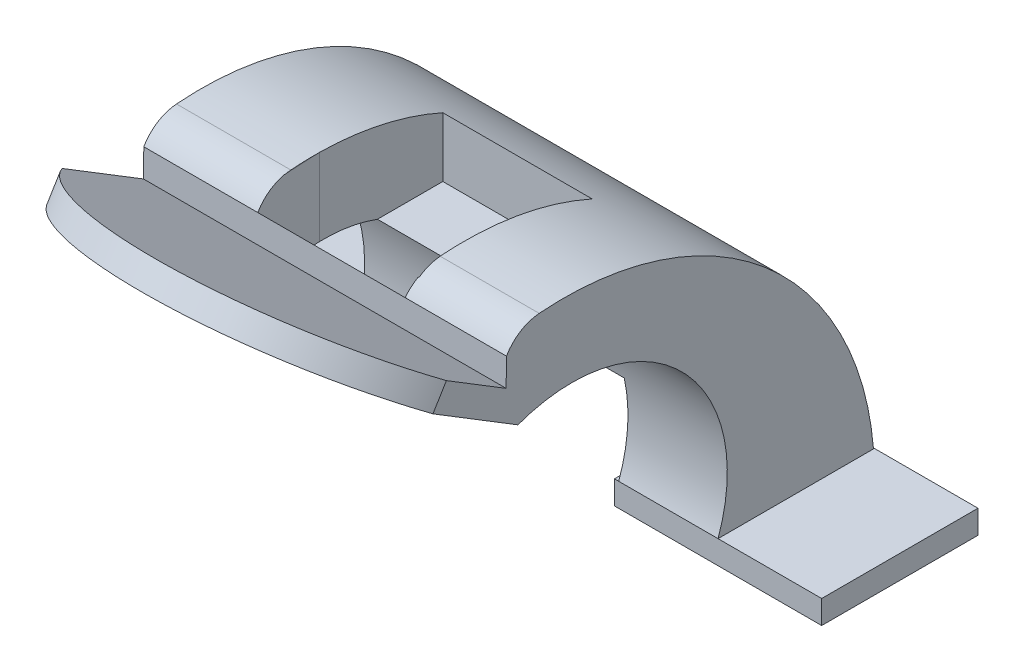
from build123d import *

# Parameters (mm, degrees)
BOSS_EXTRUDE4_DEPTH      = 70
CUT_EXTRUDE7_DEPTH       = 70
CUT_EXTRUDE8_DEPTH       = 70
CUT_EXTRUDE9_DEPTH       = 70
CUT_EXTRUDE10_DEPTH      = 70
SKETCH9_W                = 19.742548684
SKETCH9_H                = 10.626968924
CUT_EXTRUDE11_DEPTH      = 70
SKETCH10_W               = 30.173725447
SKETCH10_H               = 4.529281074
BOSS_EXTRUDE6_DEPTH      = 20
BOSS_EXTRUDE6_DEPTH_BACK = 20
SKETCH11_W               = 30.173725447
SKETCH11_H               = 4.529281074
BOSS_EXTRUDE7_DEPTH      = 20
BOSS_EXTRUDE7_DEPTH_BACK = 20
SKETCH12_W               = 12.373535054
SKETCH12_H               = 7.384206403
CUT_EXTRUDE12_DEPTH      = 60


with BuildPart() as part:
    # Sketch1 → Boss-Extrude4 (new body)
    with BuildSketch(Plane(origin=(0, 0, 0), x_dir=(0, 0, -1), z_dir=(1, 0, 0))):
        with BuildLine():
            Line((-39.22009442, -23.730076692), (-9.22009442, -23.730076692))
            ThreePointArc((-9.22009442, -23.730076692), (-30.130831643, 17.067070654), (-73.745048282, 31.190323456))
            ThreePointArc((-73.745048282, 31.190323456), (-77.395108799, 29.973959621), (-80.055244789, 27.19436266))
            Line((-80.055244789, 27.19436266), (-80.119694314, 21.843458315))
            Line((-80.119694314, 21.843458315), (-111.566080144, 41.091665162))
            ThreePointArc((-111.566080144, 41.091665162), (-114.864867075, 40.185656866), (-114.171074211, 36.835806464))
            Line((-114.171074211, 36.835806464), (-113.899114734, 36.669341157))
            Line((-113.899114734, 36.669341157), (-77.842344496, 14.599136476))
            ThreePointArc((-77.842344496, 14.599136476), (-46.303479727, 7.755753907), (-39.22009442, -23.730076692))
        make_face()
    extrude(amount=-BOSS_EXTRUDE4_DEPTH)

    # Sketch7 → Cut-Extrude7 (cut)
    with BuildSketch(Plane(origin=(0, -19.784860197, 12.110233703), x_dir=(1, 0, 0), z_dir=(0, 0.8529078546066994, -0.5220614825384052))):
        Polygon((-70, -137.087313056), (0, -134.019745414), (0, -116.607961697), (-70, -116.607961697), align=None)
        with BuildLine():
            Line((0, -116.607961697), (0, -93.251406208))
            ThreePointArc((0, -93.251406208), (-14.740425592, -110.265300978), (-36.339578744, -116.607961697))
            Line((-36.339578744, -116.607961697), (0, -116.607961697))
        make_face()
        with BuildLine():
            Line((-70, -116.607961697), (-36.339578744, -116.607961697))
            ThreePointArc((-36.339578744, -116.607961697), (-55.528547719, -111.697453308), (-70, -98.173153259))
            Line((-70, -98.173153259), (-70, -116.607961697))
        make_face()
    extrude(amount=-CUT_EXTRUDE7_DEPTH, mode=Mode.SUBTRACT)

    # 3DSketch2 → Cut-Extrude8 (cut)
    with BuildSketch(Plane(origin=(-19.171968763, -23.730076692, 9.22009442), x_dir=(-0.9120096253806464, 0.410168798439195, 0), z_dir=(0, 0, 1))):
        Polygon((0, 0), (33.948715461, 15.26815446), (40.815441858, 0), (6.866726397, -15.26815446), align=None)
    extrude(amount=CUT_EXTRUDE8_DEPTH, mode=Mode.SUBTRACT)

    # 3DSketch3 → Cut-Extrude9 (cut)
    with BuildSketch(Plane(origin=(-47.927611425, 14.599136476, 77.842344496), x_dir=(0.6530368290826427, 0, -0.7573261515765103), z_dir=(0, -1, 0))):
        Polygon((0, 0), (25.318083545, -21.831599189), (44.143312647, 0), (18.825229102, 21.831599189), align=None)
    extrude(amount=-CUT_EXTRUDE9_DEPTH, mode=Mode.SUBTRACT)

    # 3DSketch4 → Cut-Extrude10 (cut, along a direction that is not the sketch's normal)
    with BuildSketch(Plane(origin=(-19.22654119, 27.19436266, 80.055244789), x_dir=(-0.9162575030272925, 0.13334663681048042, -0.37774444085588477), z_dir=(0.12328082078814585, 0.9910694599529005, 0.050824844067318485))):
        Polygon((0, 0), (4.481258703, -10.967695522), (31.324240337, 0), (26.842981633, 10.967695522), align=None)
    extrude(amount=-CUT_EXTRUDE10_DEPTH, dir=(0, 1, 0), mode=Mode.SUBTRACT)

    # Sketch9 → Cut-Extrude11 (cut)
    with BuildSketch(Plane(origin=(3.531999691, 28.394173594, 1.456133504), x_dir=(-0.9923718250866462, 0.12311902997688387, 0.006313891965344148), z_dir=(-0.12328082078814556, -0.9910694599529005, -0.05082484406731809))):
        with Locations((33.130862907, -73.819623484)):
            Rectangle(SKETCH9_W, SKETCH9_H)
    extrude(amount=-CUT_EXTRUDE11_DEPTH, mode=Mode.SUBTRACT)

    # Sketch10 → Boss-Extrude6 (add, two sides)
    with BuildSketch(Plane(origin=(0, 0, 0), x_dir=(0, 0, -1), z_dir=(1, 0, 0))) as boss_extrude6_sk:
        with Locations((-24.133231697, -25.994717229)):
            Rectangle(SKETCH10_W, SKETCH10_H)
    extrude(amount=BOSS_EXTRUDE6_DEPTH)
    extrude(boss_extrude6_sk.sketch, amount=-BOSS_EXTRUDE6_DEPTH_BACK)

    # Sketch11 → Boss-Extrude7 (add, two sides)
    with BuildSketch(Plane.ZY.offset(70)) as boss_extrude7_sk:
        with Locations((24.133231697, -25.994717229)):
            Rectangle(SKETCH11_W, SKETCH11_H)
    extrude(amount=BOSS_EXTRUDE7_DEPTH)
    extrude(boss_extrude7_sk.sketch, amount=-BOSS_EXTRUDE7_DEPTH_BACK)

    # Sketch12 → Cut-Extrude12 (cut)
    with BuildSketch(Plane(origin=(0, 0, 9.046368973), x_dir=(-1, 0, 0), z_dir=(0, 0, -1))):
        with Locations((50.666491964, -27.012348263)):
            Rectangle(SKETCH12_W, SKETCH12_H)
    extrude(amount=-CUT_EXTRUDE12_DEPTH, mode=Mode.SUBTRACT)


solid = part.part
